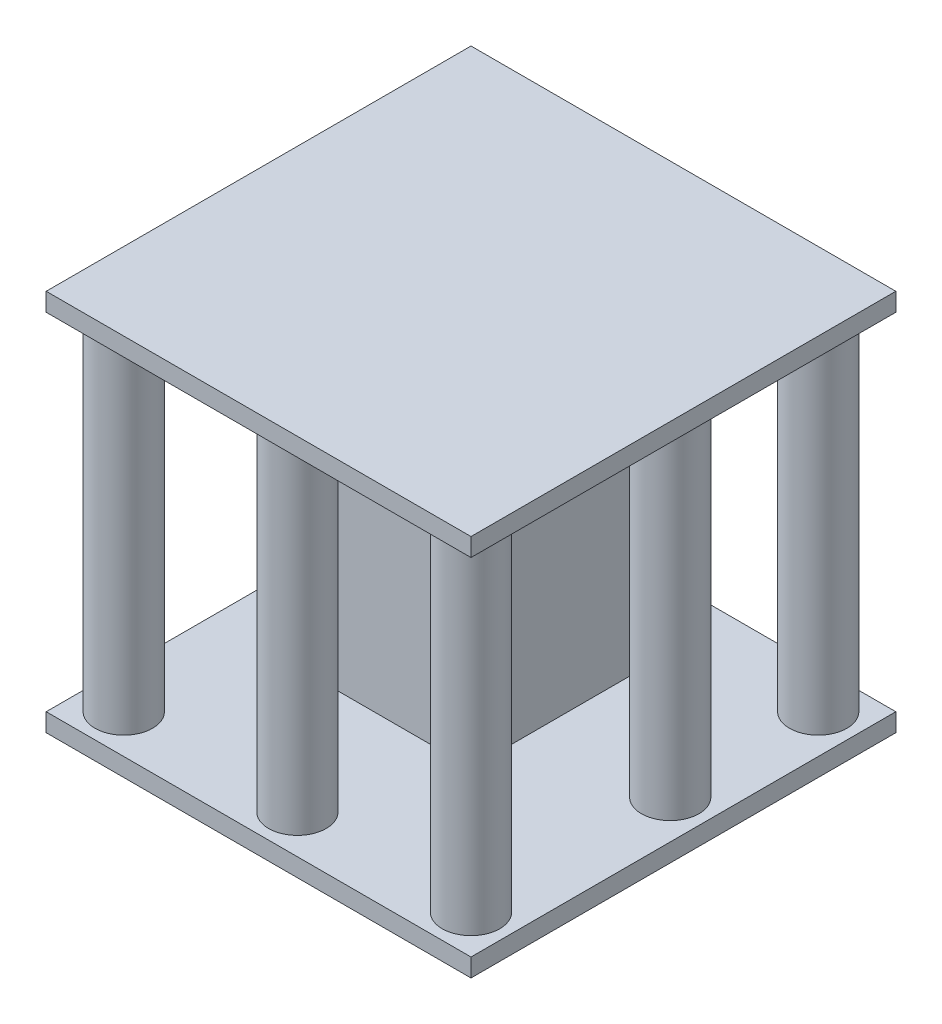
from build123d import *

# Parameters (mm, degrees)
SKETCH9_R                = 2.369598006
BOSS_EXTRUDE4_DEPTH      = 30
BOSS_EXTRUDE4_2_DEPTH    = 30
BOSS_EXTRUDE4_3_DEPTH    = 30
BOSS_EXTRUDE4_4_DEPTH    = 30
BOSS_EXTRUDE4_5_DEPTH    = 30
BOSS_EXTRUDE4_6_DEPTH    = 30
BOSS_EXTRUDE4_7_DEPTH    = 30
BOSS_EXTRUDE4_8_DEPTH    = 30
BOSS_EXTRUDE5_START      = 20
SKETCH10_W               = 15
SKETCH10_H               = 15
BOSS_EXTRUDE5_DEPTH      = 1
BOSS_EXTRUDE5_DEPTH_BACK = 15
SKETCH11_W               = 35
SKETCH11_H               = 35
BOSS_EXTRUDE6_DEPTH      = 1.5
BOSS_EXTRUDE7_START      = 30
SKETCH13_W               = 35
SKETCH13_H               = 35
BOSS_EXTRUDE7_DEPTH      = 1.5


with BuildPart() as part:
    # Sketch9 → Boss-Extrude4 (new body)
    with BuildSketch(Plane(origin=(0, 0, 0), x_dir=(1, 0, 0), z_dir=(0, 1, 0))):
        with Locations(Location((-14.303992388, 14.303992388, 0), (0, 0, 270))):  # turned: the seam where the file's is
            Circle(SKETCH9_R)
    extrude(amount=BOSS_EXTRUDE4_DEPTH)



with BuildPart() as body_2:
    # Sketch9 → Boss-Extrude4 2 (new body)
    with BuildSketch(Plane(origin=(0, 0, 0), x_dir=(1, 0, 0), z_dir=(0, 1, 0))):
        with Locations(Location((14.303992388, 14.303992388, 0), (0, 0, 270))):  # turned: the seam where the file's is
            Circle(SKETCH9_R)
    extrude(amount=BOSS_EXTRUDE4_2_DEPTH)


with BuildPart() as body_3:
    # Sketch9 → Boss-Extrude4 3 (new body)
    with BuildSketch(Plane(origin=(0, 0, 0), x_dir=(1, 0, 0), z_dir=(0, 1, 0))):
        with Locations(Location((14.303992388, -14.303992388, 0), (0, 0, 270))):  # turned: the seam where the file's is
            Circle(SKETCH9_R)
    extrude(amount=BOSS_EXTRUDE4_3_DEPTH)


with BuildPart() as body_4:
    # Sketch9 → Boss-Extrude4 4 (new body)
    with BuildSketch(Plane(origin=(0, 0, 0), x_dir=(1, 0, 0), z_dir=(0, 1, 0))):
        with Locations(Location((-14.303992388, -14.303992388, 0), (0, 0, 270))):  # turned: the seam where the file's is
            Circle(SKETCH9_R)
    extrude(amount=BOSS_EXTRUDE4_4_DEPTH)


with BuildPart() as body_5:
    # Sketch9 → Boss-Extrude4 5 (new body)
    with BuildSketch(Plane(origin=(0, 0, 0), x_dir=(1, 0, 0), z_dir=(0, 1, 0))):
        with Locations(Location((-14.303992388, 0, 0), (0, 0, 270))):  # turned: the seam where the file's is
            Circle(SKETCH9_R)
    extrude(amount=BOSS_EXTRUDE4_5_DEPTH)


with BuildPart() as body_6:
    # Sketch9 → Boss-Extrude4 6 (new body)
    with BuildSketch(Plane(origin=(0, 0, 0), x_dir=(1, 0, 0), z_dir=(0, 1, 0))):
        with Locations(Location((0, -14.303992388, 0), (0, 0, 270))):  # turned: the seam where the file's is
            Circle(SKETCH9_R)
    extrude(amount=BOSS_EXTRUDE4_6_DEPTH)


with BuildPart() as body_7:
    # Sketch9 → Boss-Extrude4 7 (new body)
    with BuildSketch(Plane(origin=(0, 0, 0), x_dir=(1, 0, 0), z_dir=(0, 1, 0))):
        with Locations(Location((14.303992388, 2.110985408, 0), (0, 0, 270))):  # turned: the seam where the file's is
            Circle(SKETCH9_R)
    extrude(amount=BOSS_EXTRUDE4_7_DEPTH)


with BuildPart() as body_8:
    # Sketch9 → Boss-Extrude4 8 (new body)
    with BuildSketch(Plane(origin=(0, 0, 0), x_dir=(1, 0, 0), z_dir=(0, 1, 0))):
        with Locations(Location((0, 14.303992388, 0), (0, 0, 270))):  # turned: the seam where the file's is
            Circle(SKETCH9_R)
    extrude(amount=BOSS_EXTRUDE4_8_DEPTH)


with BuildPart() as body_9:
    # Sketch10 → Boss-Extrude5 (new body, two sides)
    with BuildSketch(Plane(origin=(0, 0, 0), x_dir=(1, 0, 0), z_dir=(0, 1, 0)).offset(BOSS_EXTRUDE5_START)) as boss_extrude5_sk:
        Rectangle(SKETCH10_W, SKETCH10_H)
    extrude(amount=BOSS_EXTRUDE5_DEPTH)
    extrude(boss_extrude5_sk.sketch, amount=-BOSS_EXTRUDE5_DEPTH_BACK)


with BuildPart() as part_1:
    add(part.part)

    add(body_2.part)  # Boss-Extrude6 merges body 2

    add(body_3.part)  # Boss-Extrude6 merges body 3

    add(body_4.part)  # Boss-Extrude6 merges body 4

    add(body_5.part)  # Boss-Extrude6 merges body 5

    add(body_6.part)  # Boss-Extrude6 merges body 6

    add(body_7.part)  # Boss-Extrude6 merges body 7

    add(body_8.part)  # Boss-Extrude6 merges body 8
    # Sketch11 → Boss-Extrude6 (add)
    with BuildSketch(Plane(origin=(0, 0, 0), x_dir=(1, 0, 0), z_dir=(0, 1, 0))):
        Rectangle(SKETCH11_W, SKETCH11_H)
    extrude(amount=BOSS_EXTRUDE6_DEPTH)

    # Sketch13 → Boss-Extrude7 (add)
    with BuildSketch(Plane(origin=(0, 0, 0), x_dir=(1, 0, 0), z_dir=(0, 1, 0)).offset(BOSS_EXTRUDE7_START)):
        Rectangle(SKETCH13_W, SKETCH13_H)
    extrude(amount=BOSS_EXTRUDE7_DEPTH)


solid = Compound([body_9.part, part_1.part])
